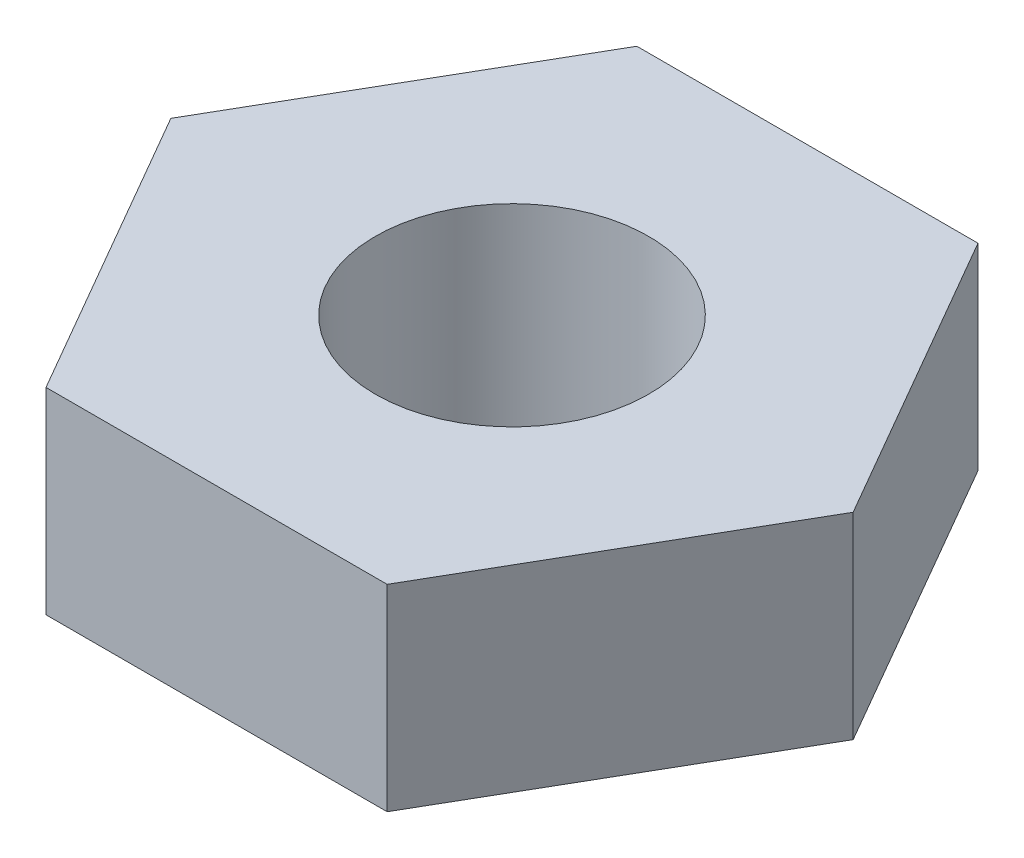
from build123d import *

# Parameters (mm, degrees)
SKETCH1_R           = 2.0828
BOSS_EXTRUDE1_DEPTH = 3


with BuildPart() as part:
    # Sketch1 → Boss-Extrude1 (new body)
    with BuildSketch(Plane(origin=(0, 0, 0), x_dir=(1, 0, 0), z_dir=(0, 1, 0))):
        Polygon((5.196152423, 0), (2.598076211, 4.5), (-2.598076211, 4.5), (-5.196152423, 0), (-2.598076211, -4.5), (2.598076211, -4.5), align=None)
        Circle(SKETCH1_R, mode=Mode.SUBTRACT)
    extrude(amount=BOSS_EXTRUDE1_DEPTH)


solid = part.part
